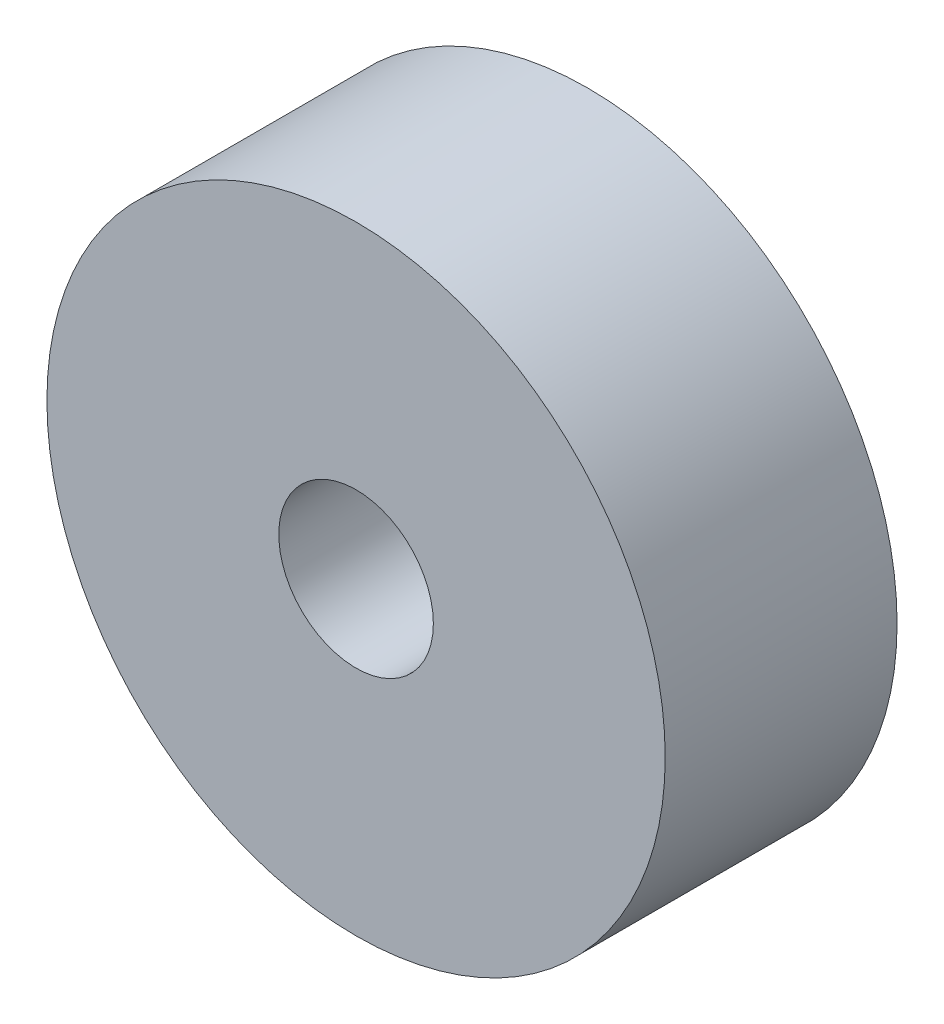
from build123d import *

# Parameters (mm, degrees)
SKETCH_1_R      = 8
SKETCH_1_R_2    = 2
EXTRUDE_1_DEPTH = 6


with BuildPart() as part:
    # 草图1 → 凸台-拉伸1 (new body)
    with BuildSketch(Plane.XY):
        Circle(SKETCH_1_R)
        Circle(SKETCH_1_R_2, mode=Mode.SUBTRACT)
    extrude(amount=EXTRUDE_1_DEPTH)


solid = part.part
